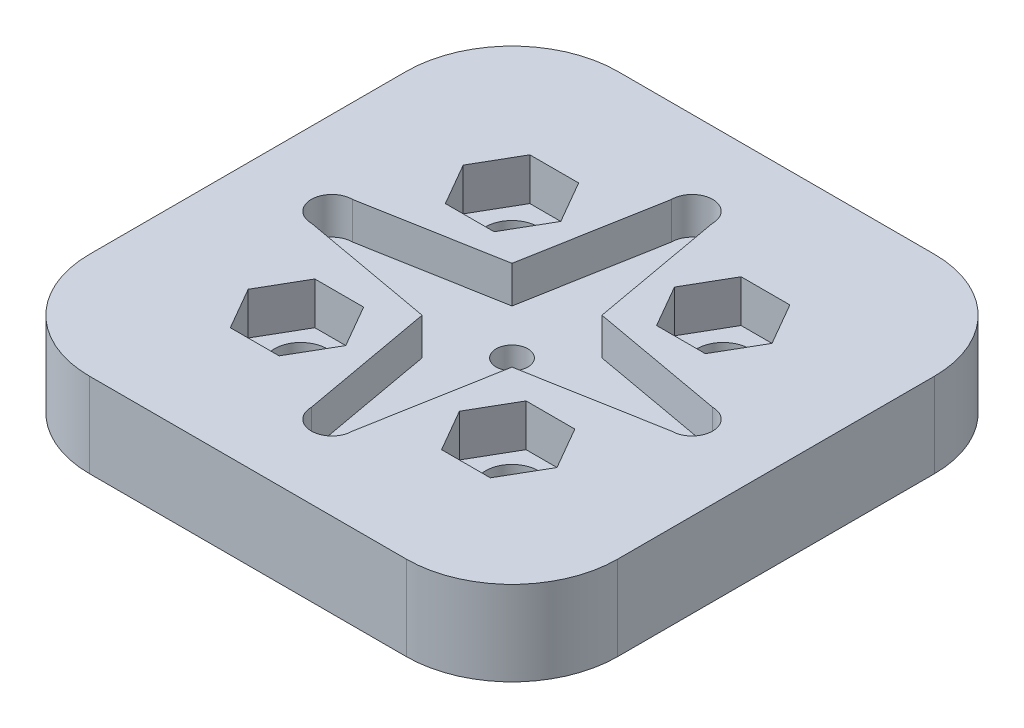
from build123d import *

# Parameters (mm, degrees)
SKETCH1_W            = 50
SKETCH1_H            = 50
BOSS_EXTRUDE1_DEPTH  = 8
SKETCH4_R            = 2.5
CUT_EXTRUDE2_DEPTH   = 9
LPATTERN1_COUNT      = 2
LPATTERN1_PITCH      = 20
LPATTERN1_COUNT_DIR2 = 2
LPATTERN1_PITCH_DIR2 = 20
FILLET2_R            = 10
CUT_EXTRUDE4_DEPTH   = 3.5
SKETCH8_R            = 1.5
CUT_EXTRUDE5_DEPTH   = 8
CUT_EXTRUDE6_DEPTH   = 4


with BuildPart() as part:
    # Sketch1 → Boss-Extrude1 (new body)
    with BuildSketch(Plane(origin=(0, 0, 0), x_dir=(1, 0, 0), z_dir=(0, 1, 0))):
        Rectangle(SKETCH1_W, SKETCH1_H)
    extrude(amount=BOSS_EXTRUDE1_DEPTH)

    # Sketch4 → Cut-Extrude2 (cut, through all)
    with BuildSketch(Plane(origin=(0, 8, 0), x_dir=(1, 0, 0), z_dir=(0, 1, 0))):
        with Locations((-10, 10)):
            Circle(SKETCH4_R)
    cut_extrude2 = extrude(amount=-CUT_EXTRUDE2_DEPTH, mode=Mode.SUBTRACT)

    # LPattern1: Cut-Extrude2 2 × 2
    with Locations(*[(i * LPATTERN1_PITCH, 0, j * LPATTERN1_PITCH_DIR2) for i in range(LPATTERN1_COUNT) for j in range(LPATTERN1_COUNT_DIR2) if (i, j) != (0, 0)]):
        add(cut_extrude2, mode=Mode.SUBTRACT)

    # Fillet2
    fillet2_edges = [part.edges().sort_by_distance(p)[0] for p in [
        (25, 4, 25),
        (-25, 4, 25),
        (-25, 4, -25),
        (25, 4, -25),
    ]]
    fillet(fillet2_edges, radius=FILLET2_R)

    # Sketch6 → Cut-Extrude4 (cut)
    with BuildSketch(Plane(origin=(0, 8, 0), x_dir=(1, 0, 0), z_dir=(0, 1, 0))):
        with BuildLine():
            Line((-4.25619416, 4.256194169), (-1.950000003, 17.050000033))
            ThreePointArc((-1.950000003, 17.050000033), (-3e-09, 19), (1.949999997, 17.050000033))
            Line((1.949999997, 17.050000033), (4.256194155, 4.256194169))
            Line((4.256194155, 4.256194169), (17.050000021, 1.950000015))
            ThreePointArc((17.050000021, 1.950000015), (19, 1.5e-08), (17.050000021, -1.949999985))
            Line((17.050000021, -1.949999985), (4.256194155, -4.256194139))
            Line((4.256194155, -4.256194139), (1.950000081, -17.050000018))
            ThreePointArc((1.950000081, -17.050000018), (8.1e-08, -19), (-1.949999919, -17.050000018))
            Line((-1.949999919, -17.050000018), (-4.25619416, -4.256194169))
            Line((-4.25619416, -4.256194169), (-17.050000023, -1.95))
            ThreePointArc((-17.050000023, -1.95), (-19, 0), (-17.050000023, 1.95))
            Line((-17.050000023, 1.95), (-4.25619416, 4.256194169))
        make_face()
    extrude(amount=-CUT_EXTRUDE4_DEPTH, mode=Mode.SUBTRACT)

    # Sketch8 → Cut-Extrude5 (cut)
    with BuildSketch(Plane.XZ):
        Circle(SKETCH8_R)
    extrude(amount=-CUT_EXTRUDE5_DEPTH, mode=Mode.SUBTRACT)

    # Sketch9 → Cut-Extrude6 (cut)
    with BuildSketch(Plane(origin=(0, 8, 0), x_dir=(1, 0, 0), z_dir=(0, 1, 0))):
        Polygon((14.618802154, 10), (12.309401077, 14), (7.690598923, 14), (5.381197846, 10), (7.690598923, 6), (12.309401077, 6), align=None)
        Polygon((-7.690598923, 14), (-12.309401077, 14), (-14.618802154, 10), (-12.309401077, 6), (-7.690598923, 6), (-5.381197846, 10), align=None)
        Polygon((14.618802154, -10.359902285), (12.309401077, -6.359902285), (7.690598923, -6.359902285), (5.381197846, -10.359902285), (7.690598923, -14.359902285), (12.309401077, -14.359902285), align=None)
        Polygon((-5.381197846, -10.359902285), (-7.690598923, -6.359902285), (-12.309401077, -6.359902285), (-14.618802154, -10.359902285), (-12.309401077, -14.359902285), (-7.690598923, -14.359902285), align=None)
    extrude(amount=-CUT_EXTRUDE6_DEPTH, mode=Mode.SUBTRACT)


solid = part.part
